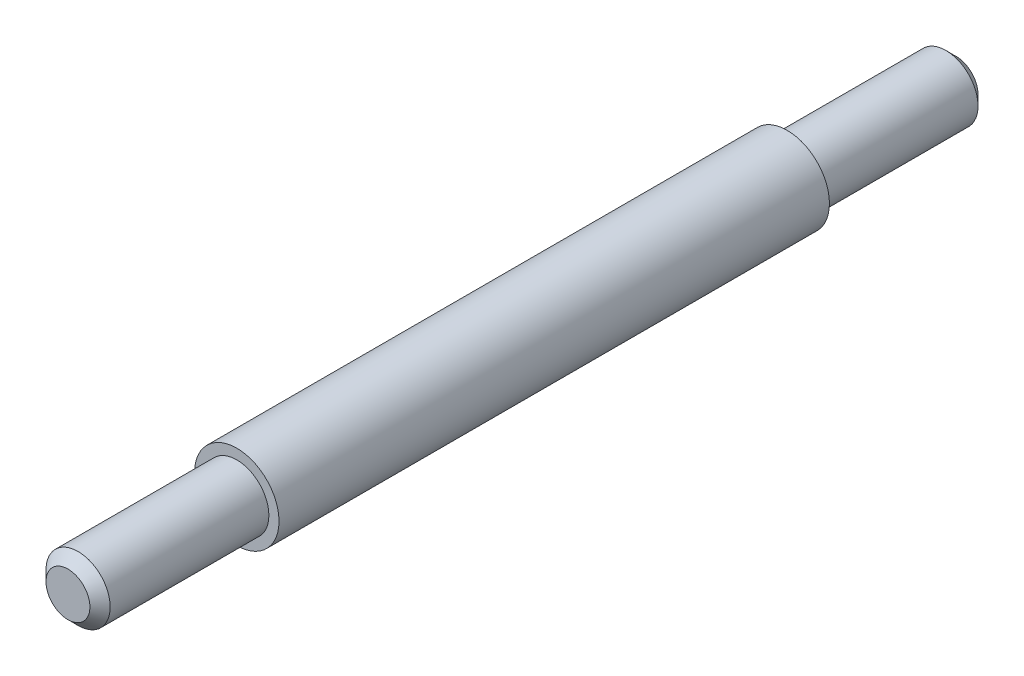
from build123d import *

# Parameters (mm, degrees)
CHAMFER1_SIZE = 0.03


with BuildPart() as part:
    # Sketch2 → Revolve1 (revolve)
    with BuildSketch(Plane(origin=(0, 0, 0), x_dir=(1, 0, 0), z_dir=(0, 1, 0))):
        Polygon((0, 0), (0.095, 0), (0.095, 0.5), (0.125, 0.5), (0.125, 2.13), (0.095, 2.13), (0.095, 2.63), (0, 2.63), align=None)
    revolve(axis=Axis((0, 0, 0), (0, 0, -1)))

    # Chamfer1
    chamfer1_edges = [part.edges().sort_by_distance(p)[0] for p in [
        (-0.095, 0, -2.63),
        (-0.095, 0, 0),
    ]]
    chamfer(chamfer1_edges, length=CHAMFER1_SIZE)


solid = part.part
